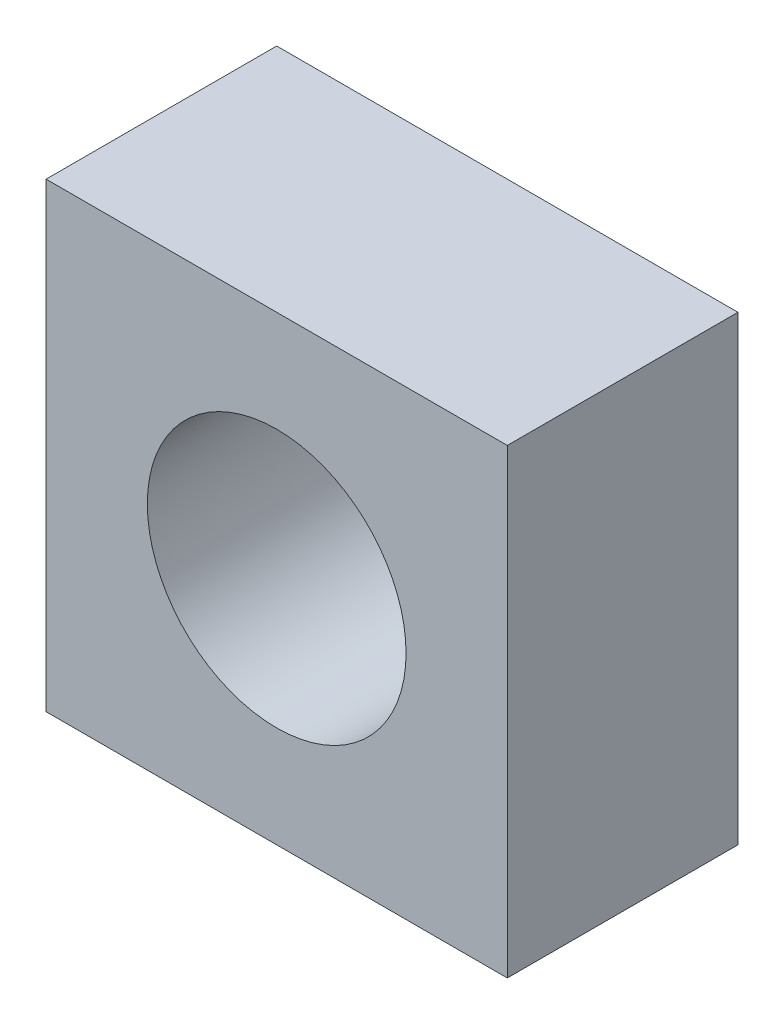
from build123d import *

# Parameters (mm, degrees)
SKETCH1_W           = 40
SKETCH1_H           = 40
SKETCH1_R           = 11.219232615
BOSS_EXTRUDE1_DEPTH = 20


with BuildPart() as part:
    # Sketch1 → Boss-Extrude1 (new body)
    with BuildSketch(Plane.XY):
        Rectangle(SKETCH1_W, SKETCH1_H)
        Circle(SKETCH1_R, mode=Mode.SUBTRACT)
    extrude(amount=BOSS_EXTRUDE1_DEPTH)


solid = part.part
